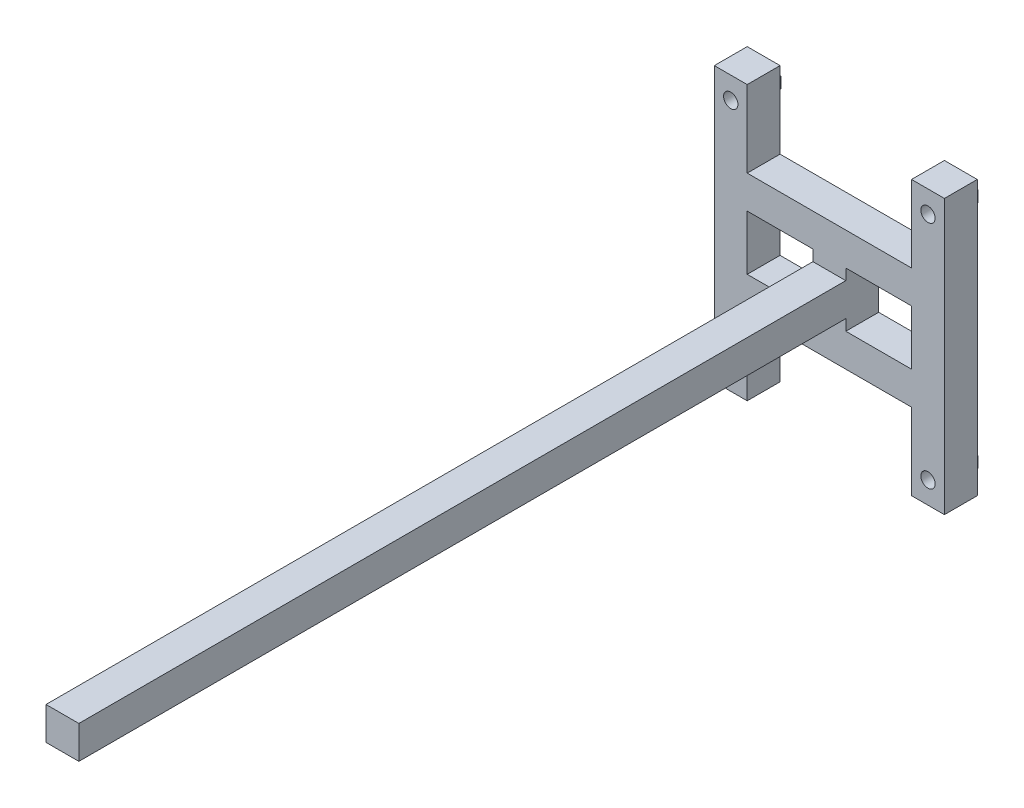
from build123d import *

# Parameters (mm, degrees)
SKETCH1_W           = 60
SKETCH1_H           = 50
BOSS_EXTRUDE1_DEPTH = 30
SKETCH2_W           = 30
SKETCH2_H           = 30
BOSS_EXTRUDE2_DEPTH = 700
SKETCH3_R           = 6
BOSS_EXTRUDE3_DEPTH = 7
CUT_EXTRUDE1_REACH  = 732
SKETCH4_R           = 6.523816089


with BuildPart() as part:
    # Sketch1 → Boss-Extrude1 (new body)
    with BuildSketch(Plane.XY):
        Polygon((-105, 125), (-75, 125), (-75, 55), (75, 55), (75, 125), (105, 125), (105, -125), (75, -125), (75, -55), (-75, -55), (-75, -125), (-105, -125), align=None)
        with Locations((-45, 0)):
            Rectangle(SKETCH1_W, SKETCH1_H, mode=Mode.SUBTRACT)
        with Locations((45, 0)):
            Rectangle(SKETCH1_W, SKETCH1_H, mode=Mode.SUBTRACT)
    extrude(amount=BOSS_EXTRUDE1_DEPTH)

    # Sketch2 → Boss-Extrude2 (add)
    with BuildSketch(Plane.XY.offset(30)):
        Rectangle(SKETCH2_W, SKETCH2_H)
    extrude(amount=BOSS_EXTRUDE2_DEPTH)

    # Sketch3 → Boss-Extrude3 (add)
    with BuildSketch(Plane(origin=(0, 0, 0), x_dir=(-1, 0, 0), z_dir=(0, 0, -1))):
        Polygon((81.339745962, 110), (90, 115), (98.660254038, 110), (98.660254038, 100), (90, 95), (81.339745962, 100), align=None)
        with Locations((90, 105)):
            Circle(SKETCH3_R, mode=Mode.SUBTRACT)
        Polygon((-90, 115), (-98.660254038, 110), (-98.660254038, 100), (-90, 95), (-81.339745962, 100), (-81.339745962, 110), align=None)
        with Locations((-90, 105)):
            Circle(SKETCH3_R, mode=Mode.SUBTRACT)
        Polygon((81.339745962, -100), (81.339745962, -110), (90, -115), (98.660254038, -110), (98.660254038, -100), (90, -95), align=None)
        with Locations((90, -105)):
            Circle(SKETCH3_R, mode=Mode.SUBTRACT)
        Polygon((-81.339745962, -110), (-90, -115), (-98.660254038, -110), (-98.660254038, -100), (-90, -95), (-81.339745962, -100), align=None)
        with Locations((-90, -105)):
            Circle(SKETCH3_R, mode=Mode.SUBTRACT)
    extrude(amount=BOSS_EXTRUDE3_DEPTH)

    # Sketch4 → Cut-Extrude1 (cut, up to next)
    with BuildSketch(Plane(origin=(0, 0, 0), x_dir=(-1, 0, 0), z_dir=(0, 0, -1)), mode=Mode.PRIVATE) as cut_extrude1_sk1:
        with Locations((-90, 105)):
            Circle(SKETCH4_R)
    cut_extrude1_tool1 = extrude(cut_extrude1_sk1.sketch, amount=-CUT_EXTRUDE1_REACH, mode=Mode.PRIVATE) & part.part
    add(cut_extrude1_tool1.solids().sort_by_distance((90, 105, 0))[0], mode=Mode.SUBTRACT)
    # Sketch4 → Cut-Extrude1 (cut, up to next)
    with BuildSketch(Plane(origin=(0, 0, 0), x_dir=(-1, 0, 0), z_dir=(0, 0, -1)), mode=Mode.PRIVATE) as cut_extrude1_sk2:
        with Locations((90, 105)):
            Circle(SKETCH4_R)
    cut_extrude1_tool2 = extrude(cut_extrude1_sk2.sketch, amount=-CUT_EXTRUDE1_REACH, mode=Mode.PRIVATE) & part.part
    add(cut_extrude1_tool2.solids().sort_by_distance((-90, 105, 0))[0], mode=Mode.SUBTRACT)
    # Sketch4 → Cut-Extrude1 (cut, up to next)
    with BuildSketch(Plane(origin=(0, 0, 0), x_dir=(-1, 0, 0), z_dir=(0, 0, -1)), mode=Mode.PRIVATE) as cut_extrude1_sk3:
        with Locations((90, -105)):
            Circle(SKETCH4_R)
    cut_extrude1_tool3 = extrude(cut_extrude1_sk3.sketch, amount=-CUT_EXTRUDE1_REACH, mode=Mode.PRIVATE) & part.part
    add(cut_extrude1_tool3.solids().sort_by_distance((-90, -105, 0))[0], mode=Mode.SUBTRACT)
    # Sketch4 → Cut-Extrude1 (cut, up to next)
    with BuildSketch(Plane(origin=(0, 0, 0), x_dir=(-1, 0, 0), z_dir=(0, 0, -1)), mode=Mode.PRIVATE) as cut_extrude1_sk4:
        with Locations((-90, -105)):
            Circle(SKETCH4_R)
    cut_extrude1_tool4 = extrude(cut_extrude1_sk4.sketch, amount=-CUT_EXTRUDE1_REACH, mode=Mode.PRIVATE) & part.part
    add(cut_extrude1_tool4.solids().sort_by_distance((90, -105, 0))[0], mode=Mode.SUBTRACT)


solid = part.part
